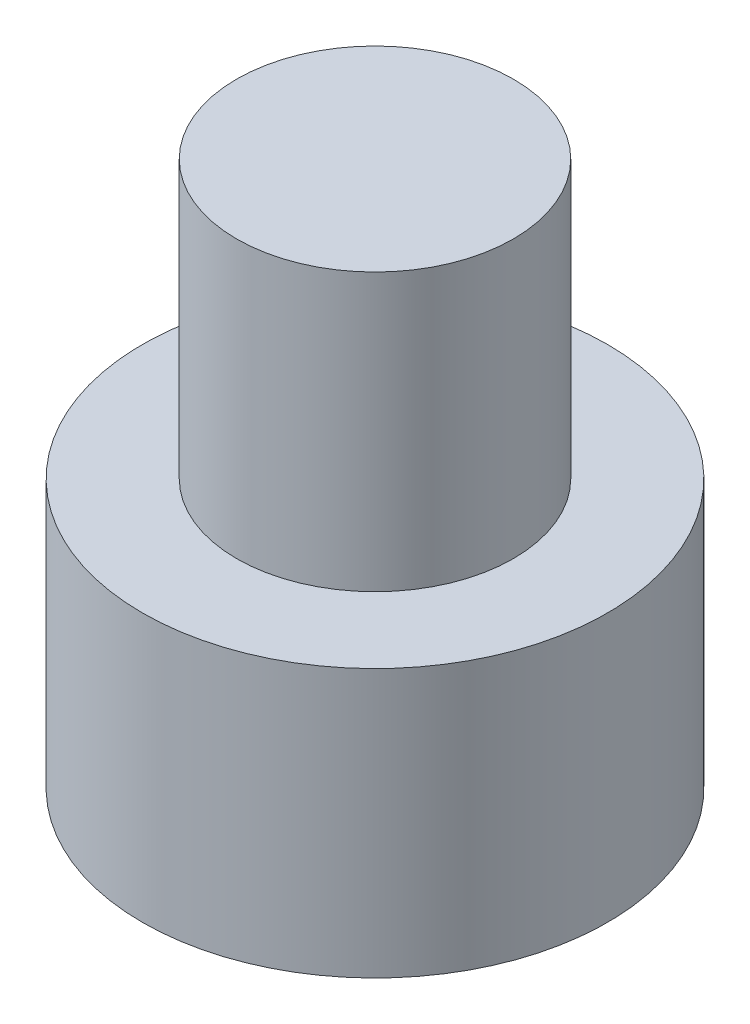
from build123d import *

# Parameters (mm, degrees)
SKETCH_1_R          = 4.2
EXTRUDE_1_DEPTH     = 4.84
SKETCH_2_R          = 2.5
EXTRUDE_2_DEPTH     = 5
CUT_EXTRUDE_1_DEPTH = 3.4


with BuildPart() as part:
    # 草图1 → 凸台-拉伸1 (new body)
    with BuildSketch(Plane(origin=(0, 0, 0), x_dir=(1, 0, 0), z_dir=(0, 1, 0))):
        Circle(SKETCH_1_R)
    extrude(amount=EXTRUDE_1_DEPTH)

    # 草图2 → 凸台-拉伸2 (add)
    with BuildSketch(Plane(origin=(0, 4.84, 0), x_dir=(1, 0, 0), z_dir=(0, 1, 0))):
        Circle(SKETCH_2_R)
    extrude(amount=EXTRUDE_2_DEPTH)

    # 草图3 → 切除-拉伸1 (cut)
    with BuildSketch(Plane.XZ):
        Polygon((2.3, 0), (1.15, 1.991858429), (-1.15, 1.991858429), (-2.3, 0), (-1.15, -1.991858429), (1.15, -1.991858429), align=None)
    extrude(amount=-CUT_EXTRUDE_1_DEPTH, mode=Mode.SUBTRACT)


solid = part.part
